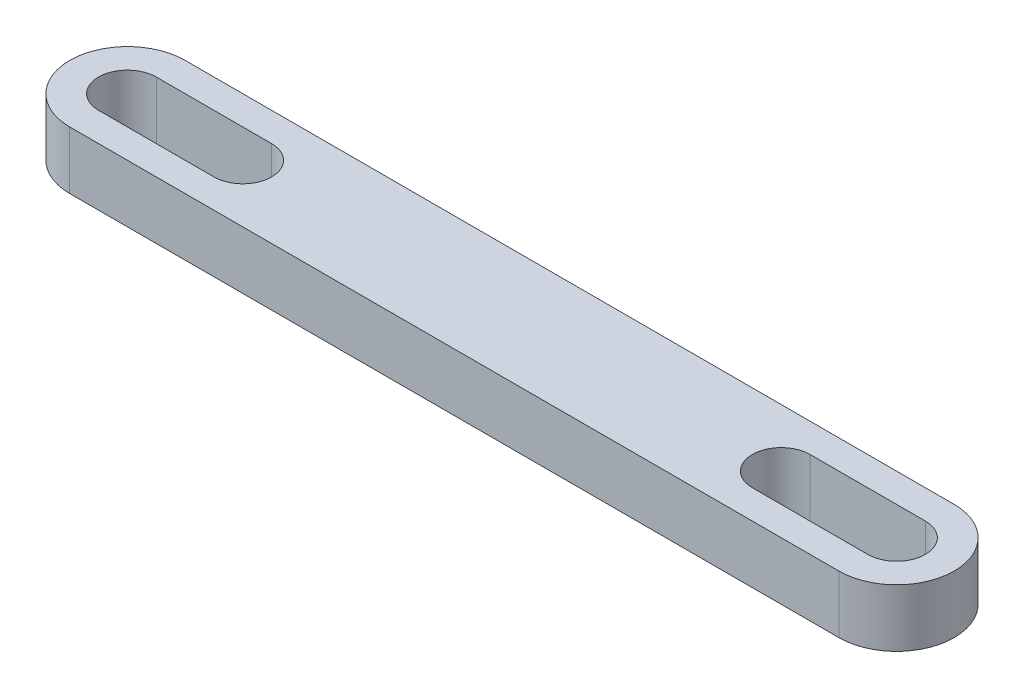
from build123d import *

# Parameters (mm, degrees)
BOSS_EXTRUDE1_DEPTH = 3


with BuildPart() as part:
    # Sketch1 → Boss-Extrude1 (new body)
    with BuildSketch(Plane(origin=(0, 0, 0), x_dir=(1, 0, 0), z_dir=(0, 1, 0))):
        with BuildLine():
            Line((0, 0), (-40, 0))
            ThreePointArc((-40, 0), (-43, 3), (-40, 6))
            Line((-40, 6), (0, 6))
            ThreePointArc((0, 6), (3, 3), (0, 0))
        make_face()
        with BuildLine():
            Line((-40, 4.5), (-34, 4.5))
            ThreePointArc((-34, 4.5), (-32.5, 3), (-34, 1.5))
            Line((-34, 1.5), (-40, 1.5))
            ThreePointArc((-40, 1.5), (-41.5, 3), (-40, 4.5))
        make_face(mode=Mode.SUBTRACT)
        with BuildLine():
            Line((0, 1.5), (-6, 1.5))
            ThreePointArc((-6, 1.5), (-7.5, 3), (-6, 4.5))
            Line((-6, 4.5), (0, 4.5))
            ThreePointArc((0, 4.5), (1.5, 3), (0, 1.5))
        make_face(mode=Mode.SUBTRACT)
    extrude(amount=BOSS_EXTRUDE1_DEPTH)


solid = part.part
